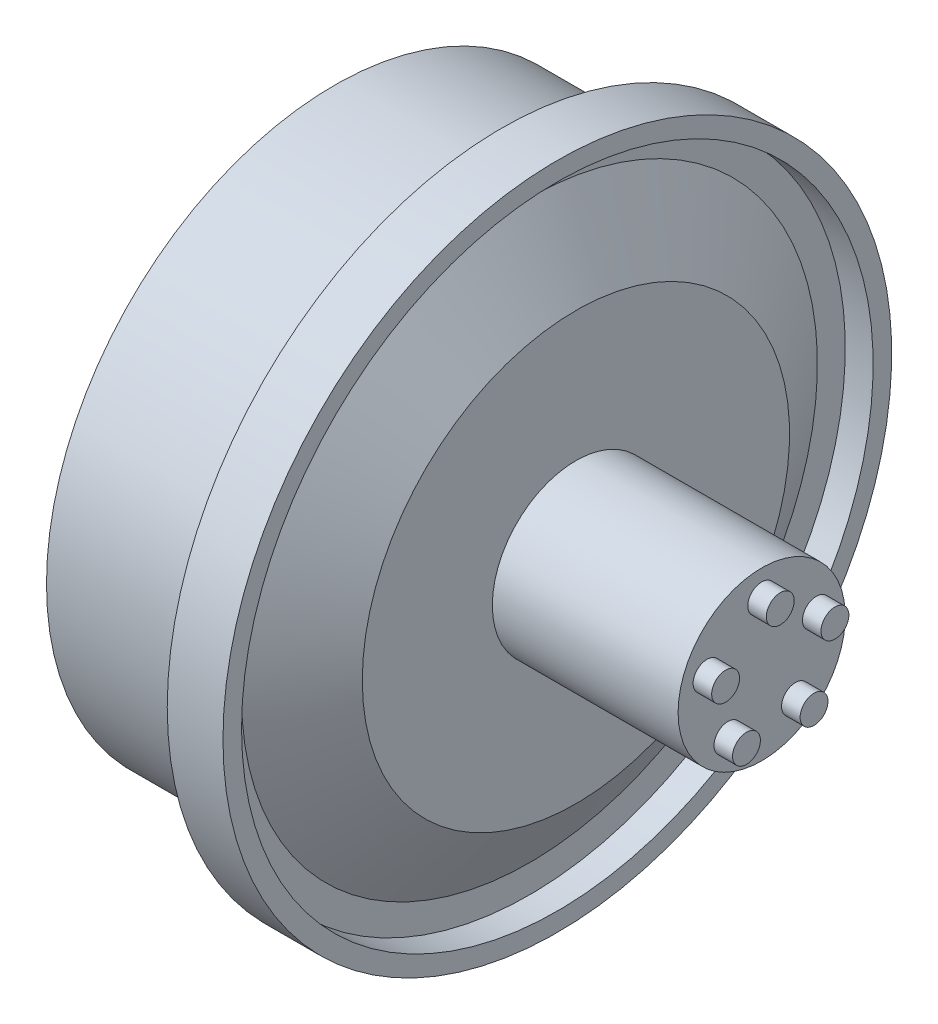
from build123d import *

# Parameters (mm, degrees)
SKETCH4_R           = 0.75
BOSS_EXTRUDE2_DEPTH = 1


with BuildPart() as part:
    # Sketch1 → Revolve1 (revolve)
    with BuildSketch(Plane(origin=(0, 0, 0), x_dir=(1, 0, 0), z_dir=(0, 1, 0))):
        Polygon((-7.620406457, 0), (-7.620406457, 15.5), (1.379593543, 15.5), (1.379593543, 18), (3.379593543, 18), (4.379593543, 18), (4.379593543, 17), (3.379593543, 17), (2.879593543, 17), (2.879593543, 15.5), (5.379593543, 11.5), (5.379593543, 4.5), (15.379593543, 4.5), (15.379593543, 3.7), (15.379593543, 0), (14.579593543, 0), (5.379593543, 0), align=None)
    revolve(axis=Axis((-25, 0, 0), (1, 0, 0)))

    # Sketch4 → Boss-Extrude2 (add)
    with BuildSketch(Plane(origin=(15.379593543, 0, 0), x_dir=(0, 0, -1), z_dir=(1, 0, 0))):
        with Locations((0, 3.093773222)):
            Circle(SKETCH4_R)
        with Locations((2.942353182, 0.956028502)):
            Circle(SKETCH4_R)
        with Locations((1.818474274, -2.502915113)):
            Circle(SKETCH4_R)
        with Locations((-1.818474274, -2.502915113)):
            Circle(SKETCH4_R)
        with Locations((-2.942353182, 0.956028502)):
            Circle(SKETCH4_R)
    extrude(amount=BOSS_EXTRUDE2_DEPTH)


solid = part.part
